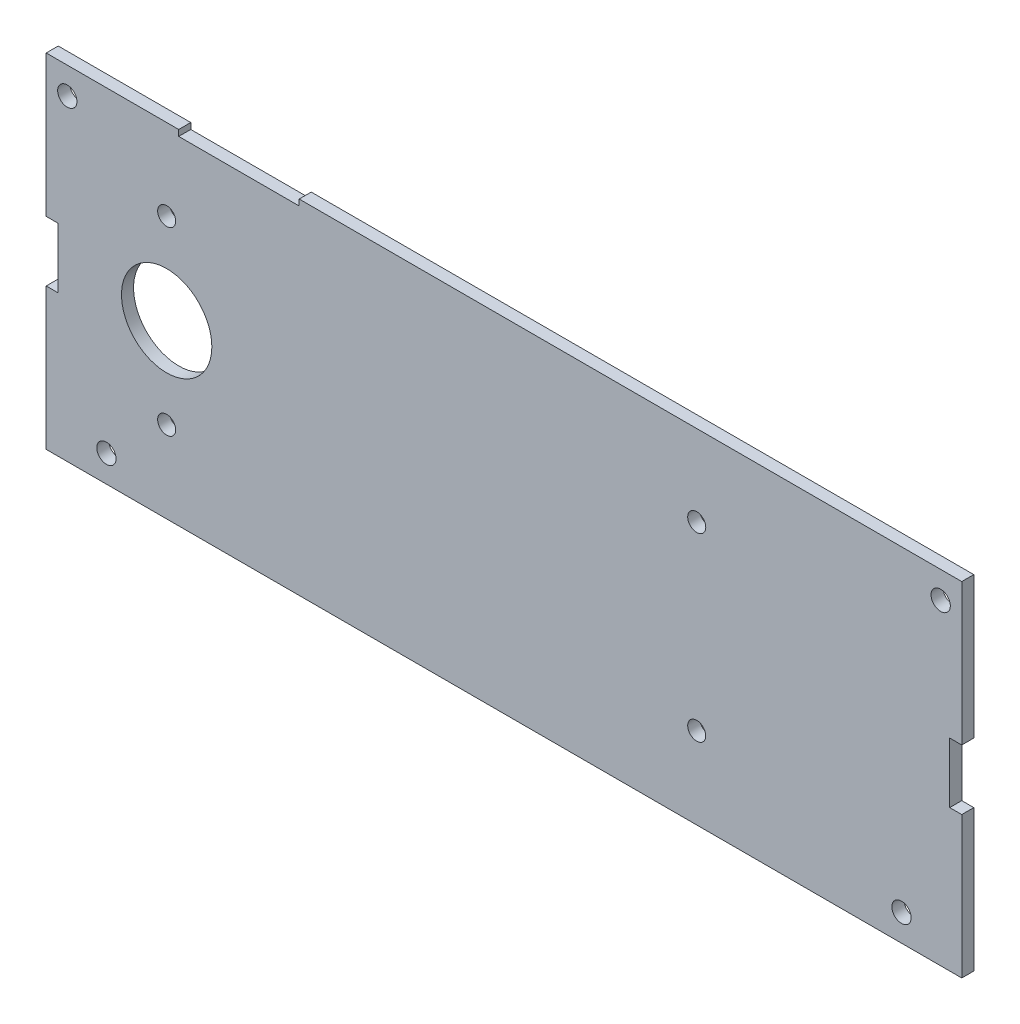
from build123d import *

# Parameters (mm, degrees)
BOSS_EXTRUDE1_DEPTH     = 2
SKETCH2_R               = 1.6
SKETCH2_R_2             = 7.5
CUT_EXTRUDE1_DEPTH      = 3
SKETCH3_R               = 1.5
SKETCH3_W               = 20
SKETCH3_H               = 1
CUT_EXTRUDE2_DEPTH      = 1
CUT_EXTRUDE2_DEPTH_BACK = 3


with BuildPart() as part:
    # Sketch1 → Boss-Extrude1 (new body)
    with BuildSketch(Plane.XY):
        Polygon((76, 28.5), (-76, 28.5), (-76, 5), (-74, 5), (-74, -5), (-76, -5), (-76, -28.5), (76, -28.5), (76, -5), (74, -5), (74, 5), (76, 5), align=None)
    extrude(amount=BOSS_EXTRUDE1_DEPTH)

    # Sketch2 → Cut-Extrude1 (cut, through all)
    with BuildSketch(Plane.XY.offset(2)):
        with Locations((-72.5, 24.05)):
            Circle(SKETCH2_R)
        with Locations((72.5, 24.05)):
            Circle(SKETCH2_R)
        with Locations((66, -24.05)):
            Circle(SKETCH2_R)
        with Locations((-66, -24.05)):
            Circle(SKETCH2_R)
        with Locations((-56, 0)):
            Circle(SKETCH2_R_2)
    extrude(amount=-CUT_EXTRUDE1_DEPTH, mode=Mode.SUBTRACT)

    # Sketch3 → Cut-Extrude2 (cut, two sides)
    with BuildSketch(Plane.XY.offset(2)) as cut_extrude2_sk:
        with Locations((32, -14.95)):
            Circle(SKETCH3_R)
        with Locations((-56, 15.05)):
            Circle(SKETCH3_R)
        with Locations((-56, -14.95)):
            Circle(SKETCH3_R)
        with Locations((32, 15.05)):
            Circle(SKETCH3_R)
        with Locations((-44, 28)):
            Rectangle(SKETCH3_W, SKETCH3_H)
    extrude(amount=CUT_EXTRUDE2_DEPTH, mode=Mode.SUBTRACT)
    extrude(cut_extrude2_sk.sketch, amount=-CUT_EXTRUDE2_DEPTH_BACK, mode=Mode.SUBTRACT)


solid = part.part
